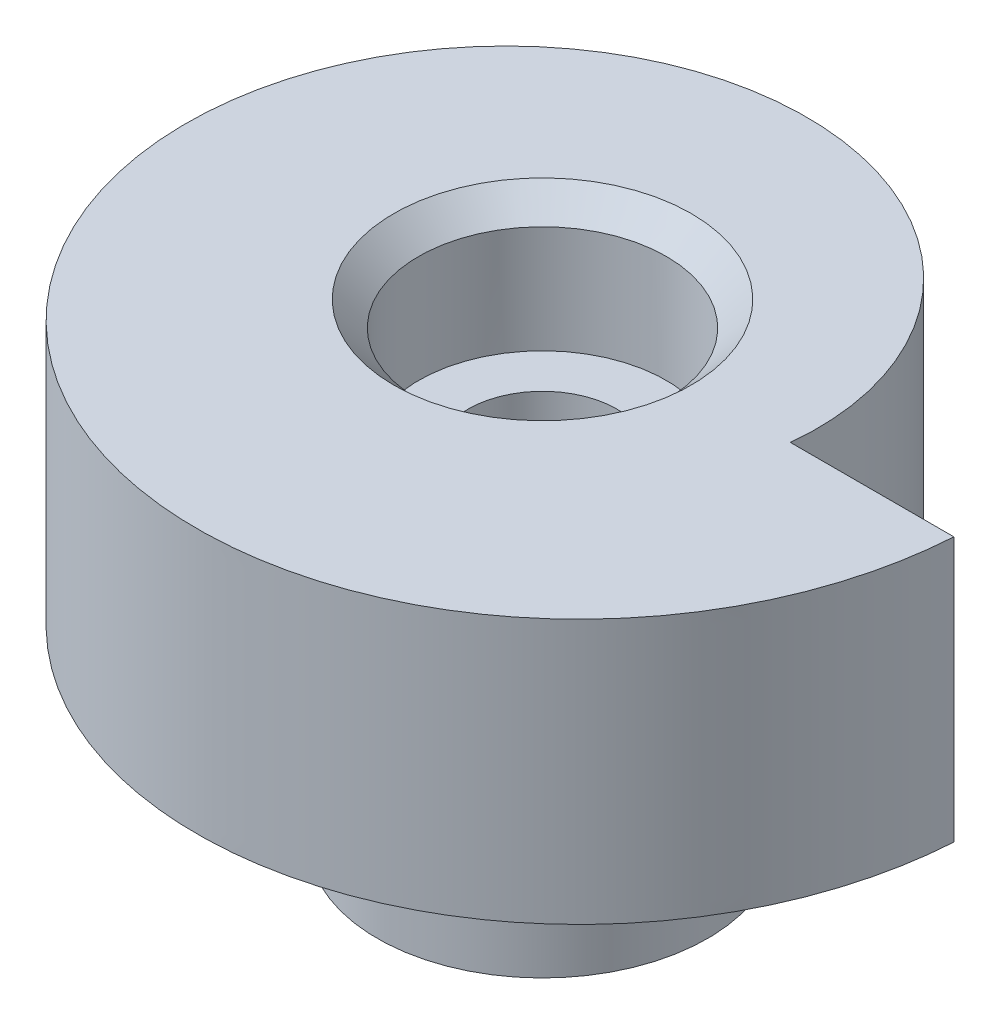
from build123d import *

# Parameters (mm, degrees)
SKETCH_1_R          = 1.8
EXTRUDE_1_DEPTH     = 6.4
SKETCH_7_R          = 3
CUT_EXTRUDE_1_DEPTH = 3.2
CHAMFER_1_SIZE      = 0.6
SKETCH_8_R          = 4
SKETCH_8_R_2        = 1.8
EXTRUDE_2_DEPTH     = 5
SKETCH_9_R          = 5.65
SKETCH_9_R_2        = 4
CUT_EXTRUDE_2_DEPTH = 2


with BuildPart() as part:
    # Эскиз1 → Бобышка-Вытянуть1 (new body)
    with BuildSketch(Plane(origin=(0, 0, 0), x_dir=(1, 0, 0), z_dir=(0, 1, 0))):
        with BuildLine():
            Line((6, 0), (9.958406744, 0))
            add(Edge.make_bspline(
                [(6, 0), (6.002272113, 0.021639174), (6.006529407, 0.064971678), (6.015112598, 0.163427407), (6.024775509, 0.304129478), (6.030478934, 0.434809211), (6.033334434, 0.586716982), (6.032690583, 0.73827041), (6.027179884, 0.917587714), (6.010615451, 1.172313346), (5.977069804, 1.476758321), (5.918236292, 1.829501116), (5.824427259, 2.227172291), (5.704652114, 2.617866963), (5.559586468, 2.999854381), (5.390015398, 3.37162893), (5.19680319, 3.731668412), (4.980898847, 4.078578375), (4.683933464, 4.49412557), (4.286417683, 4.961346959), (3.767682288, 5.455500007), (3.109527716, 5.942482642), (2.396776267, 6.345253396), (1.640568289, 6.658816766), (0.655269827, 6.9348581), (-0.364309039, 7.052809796), (-1.389575446, 7.010898818), (-2.594207276, 6.774307442), (-3.752583959, 6.357368572), (-4.993966669, 5.625704065), (-6.195596017, 4.500381965), (-7.127759938, 3.143923409), (-7.87695686, 1.320366061), (-8.180095948, -1.059949049), (-7.699390251, -3.435390648), (-6.512391275, -5.521956271), (-5.075747859, -6.990123604), (-3.724412466, -7.925022405), (-2.222268119, -8.590173964), (-0.623254184, -8.96626176), (1.017251524, -9.044338961), (2.64479309, -8.825696647), (4.207248475, -8.321045328), (5.475341442, -7.646118032), (6.464647424, -6.917652279), (7.212483615, -6.22094648), (7.760623375, -5.614225587), (8.254896543, -4.962890636), (8.692017546, -4.271907538), (9.022022694, -3.637148435), (9.265934425, -3.074854387), (9.442641195, -2.595861785), (9.567873004, -2.207063914), (9.676789888, -1.813460825), (9.769263478, -1.415482574), (9.835643513, -1.064750616), (9.878366151, -0.785836788), (9.904303789, -0.586478316), (9.918920643, -0.459345016), (9.929802018, -0.353837425), (9.942380024, -0.217342139), (9.951035172, -0.108219013), (9.955659249, -0.043429627), (9.958406744, 0)],
                knots=[0.06216236, 0.06216236, 0.06216236, 0.06216236, 0.06216236, 0.063892833, 0.065623306, 0.069084252, 0.070814725, 0.072545198, 0.076006145, 0.079467091, 0.082928037, 0.08984993, 0.09677185, 0.10369377, 0.110615691, 0.117537611, 0.124459543, 0.131381476, 0.138303408, 0.14522534, 0.159069147, 0.172912954, 0.18675682, 0.200600685, 0.214444528, 0.22828837, 0.255976018, 0.269819885, 0.283663751, 0.311351426, 0.339039092, 0.366726833, 0.39441446, 0.422102194, 0.471739609, 0.527114886, 0.554802546, 0.582490205, 0.610177862, 0.63786552, 0.665553157, 0.693240795, 0.720928452, 0.748616109, 0.776303777, 0.790147611, 0.803991445, 0.817835273, 0.831679101, 0.845522928, 0.859366756, 0.866288677, 0.873210599, 0.88013252, 0.887054442, 0.893976363, 0.900898285, 0.904359246, 0.906089726, 0.907820206, 0.909550687, 0.911281167, 0.914742128, 0.914742128, 0.914742128, 0.914742128, 0.914742128], degree=4))
        make_face()
        Circle(SKETCH_1_R, mode=Mode.SUBTRACT)
    extrude(amount=EXTRUDE_1_DEPTH)

    # Эскиз7 → Вырез-Вытянуть1 (cut)
    with BuildSketch(Plane(origin=(0, 6.4, 0), x_dir=(1, 0, 0), z_dir=(0, 1, 0))):
        Circle(SKETCH_7_R)
    extrude(amount=-CUT_EXTRUDE_1_DEPTH, mode=Mode.SUBTRACT)

    # Фаска1
    chamfer_1_edges = [part.edges().sort_by_distance(p)[0] for p in [
        (-3, 6.4, 0),
    ]]
    chamfer(chamfer_1_edges, length=CHAMFER_1_SIZE)

    # Эскиз8 → Бобышка-Вытянуть2 (add)
    with BuildSketch(Plane.XZ):
        Circle(SKETCH_8_R)
        Circle(SKETCH_8_R_2, mode=Mode.SUBTRACT)
    extrude(amount=EXTRUDE_2_DEPTH)

    # Эскиз9 → Вырез-Вытянуть2 (cut)
    with BuildSketch(Plane.XZ):
        Circle(SKETCH_9_R)
        Circle(SKETCH_9_R_2, mode=Mode.SUBTRACT)
    extrude(amount=-CUT_EXTRUDE_2_DEPTH, mode=Mode.SUBTRACT)


solid = part.part
